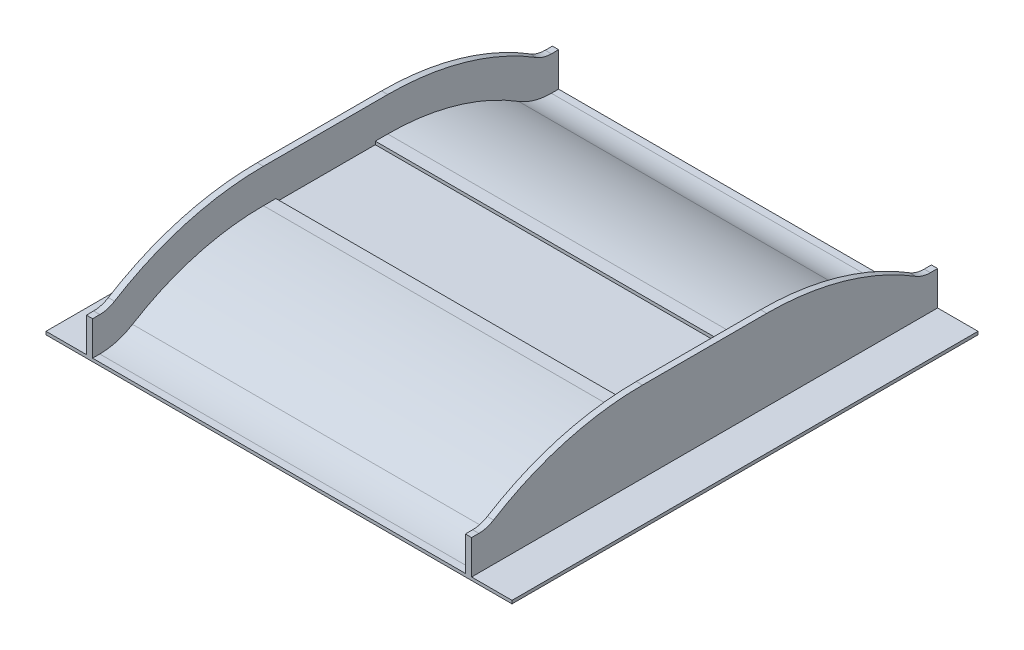
from build123d import *

# Parameters (mm, degrees)
SKETCH2_W           = 1500
SKETCH2_H           = 1500
BOSS_EXTRUDE1_DEPTH = 10
BOSS_EXTRUDE3_DEPTH = 1240
BOSS_EXTRUDE4_DEPTH = 20
SKETCH6_W           = 1200
SKETCH6_H           = 320
CUT_EXTRUDE1_DEPTH  = 10


with BuildPart() as part:
    # Sketch2 → Boss-Extrude1 (new body)
    with BuildSketch(Plane(origin=(0, 0, 0), x_dir=(1, 0, 0), z_dir=(0, 1, 0))):
        Rectangle(SKETCH2_W, SKETCH2_H)
    extrude(amount=BOSS_EXTRUDE1_DEPTH)

    # Sketch4 → Boss-Extrude3 (add)
    with BuildSketch(Plane.ZY.offset(620)):
        with BuildLine():
            ThreePointArc((-621.426146358, 40.000002328), (-672.010429767, 17.646159988), (-726.782687643, 10))
            Line((-726.782687643, 10), (726.782687643, 10))
            ThreePointArc((726.782687643, 10), (672.010424989, 17.646161349), (621.426137912, 40.000007562))
            ThreePointArc((621.426137912, 40.000007562), (419.089016099, 129.415364432), (200, 160))
            Line((200, 160), (-200, 160))
            ThreePointArc((-200, 160), (-419.089020877, 129.415363072), (-621.426146358, 40.000002328))
        make_face()
    extrude(amount=-BOSS_EXTRUDE3_DEPTH)

    # Sketch5 → Boss-Extrude4 (add)
    with BuildSketch(Plane.ZY.offset(620)):
        with BuildLine():
            Line((-750, 120), (-750, 10))
            Line((-750, 10), (-726.782687643, 10))
            ThreePointArc((-726.782687643, 10), (-672.010429767, 17.646159988), (-621.426146358, 40.000002328))
            ThreePointArc((-621.426146358, 40.000002328), (-419.089020877, 129.415363072), (-200, 160))
            Line((-200, 160), (200, 160))
            ThreePointArc((200, 160), (419.089016099, 129.415364432), (621.426137912, 40.000007562))
            ThreePointArc((621.426137912, 40.000007562), (672.010424989, 17.646161349), (726.782687643, 10))
            Line((726.782687643, 10), (750, 10))
            Line((750, 10), (750, 120))
            Line((750, 120), (726.782687643, 120))
            ThreePointArc((726.782687643, 120), (702.135172555, 123.440771722), (679.372245755, 133.5))
            ThreePointArc((679.372245755, 133.5), (449.213763665, 235.209974806), (200, 270))
            Line((200, 270), (-200, 270))
            ThreePointArc((-200, 270), (-449.213763665, 235.209974806), (-679.372245755, 133.5))
            ThreePointArc((-679.372245755, 133.5), (-702.135172555, 123.440771722), (-726.782687643, 120))
            Line((-726.782687643, 120), (-750, 120))
        make_face()
    boss_extrude4 = extrude(amount=-BOSS_EXTRUDE4_DEPTH)

    # Mirror1: Boss-Extrude4 across plane
    add(boss_extrude4.mirror(Plane(origin=(0, 0, 0), x_dir=(0, 0, 1), z_dir=(1, 0, 0))))

    # Sketch6 → Cut-Extrude1 (cut)
    with BuildSketch(Plane(origin=(0, 160, 0), x_dir=(1, 0, 0), z_dir=(0, 1, 0))):
        Rectangle(SKETCH6_W, SKETCH6_H)
    extrude(amount=-CUT_EXTRUDE1_DEPTH, mode=Mode.SUBTRACT)


solid = part.part
